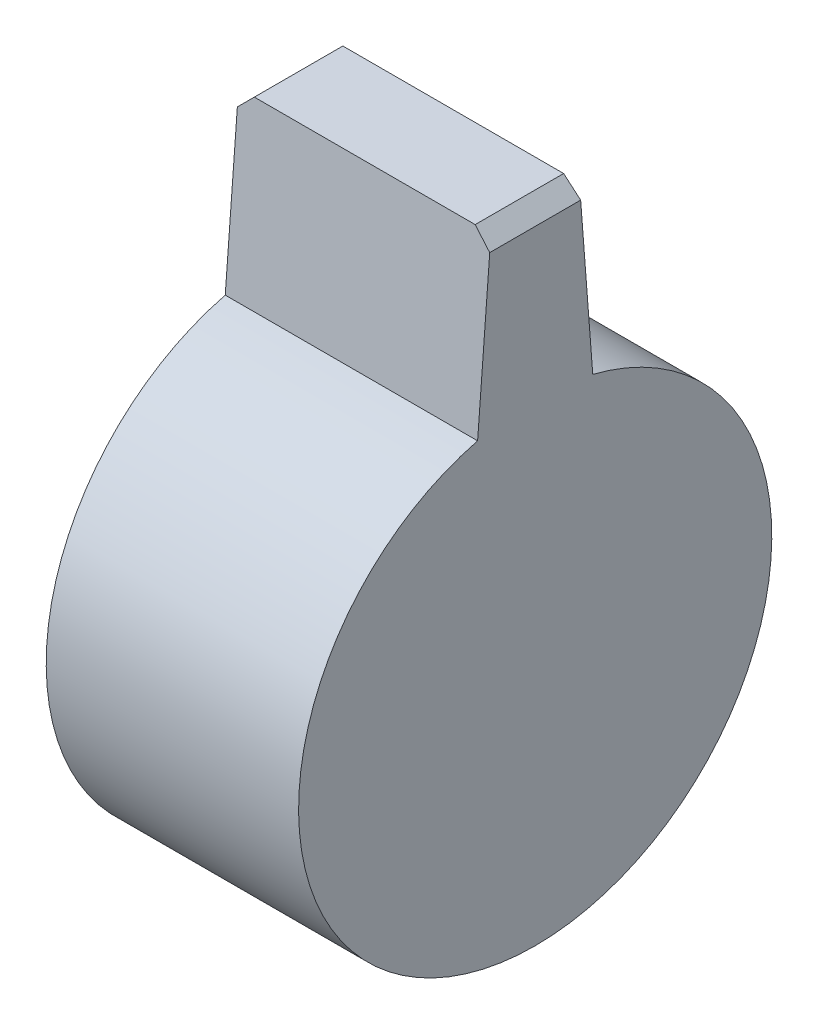
from build123d import *

# Parameters (mm, degrees)
BOSS_EXTRUDE1_DEPTH = 16
CHAMFER1_SIZE       = 1


with BuildPart() as part:
    # Sketch1 → Boss-Extrude1 (new body)
    with BuildSketch(Plane(origin=(0, 0, 0), x_dir=(0, 0, -1), z_dir=(1, 0, 0))):
        with BuildLine():
            Line((-3.65, 14.549140868), (-2.805, 25.5))
            Line((-2.805, 25.5), (2.805, 25.5))
            Line((2.805, 25.5), (3.65, 14.549140868))
            ThreePointArc((3.65, 14.549140868), (0, -15), (-3.65, 14.549140868))
        make_face()
    extrude(amount=BOSS_EXTRUDE1_DEPTH)

    # Chamfer1
    chamfer1_edges = [part.edges().sort_by_distance(p)[0] for p in [
        (0, 25.5, 0),
        (16, 25.5, 0),
    ]]
    chamfer(chamfer1_edges, length=CHAMFER1_SIZE)


solid = part.part
